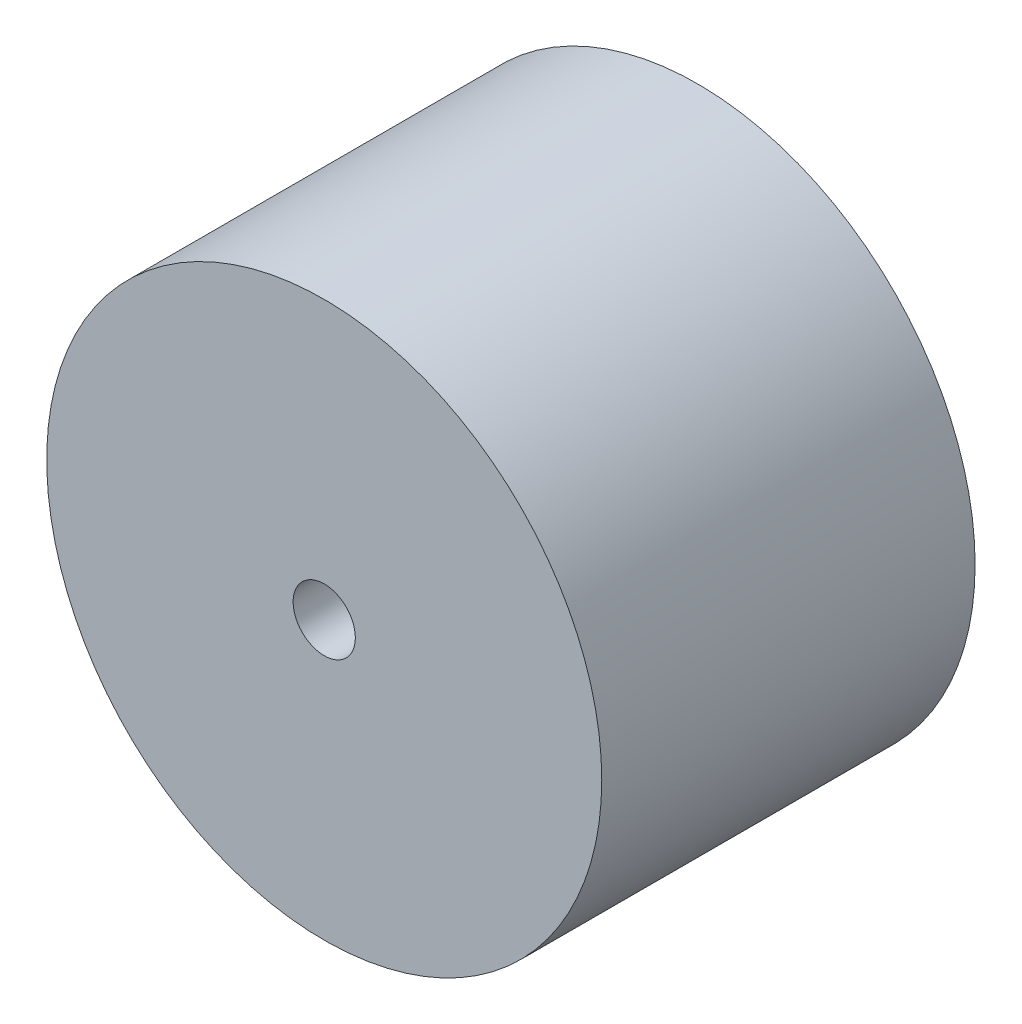
from build123d import *

# Parameters (mm, degrees)
SKETCH2_R           = 28.321
SKETCH2_R_2         = 3.175
BOSS_EXTRUDE1_DEPTH = 38.1


with BuildPart() as part:
    # Sketch2 → Boss-Extrude1 (new body)
    with BuildSketch(Plane.XY):
        Circle(SKETCH2_R)
        Circle(SKETCH2_R_2, mode=Mode.SUBTRACT)
    extrude(amount=BOSS_EXTRUDE1_DEPTH)


solid = part.part
